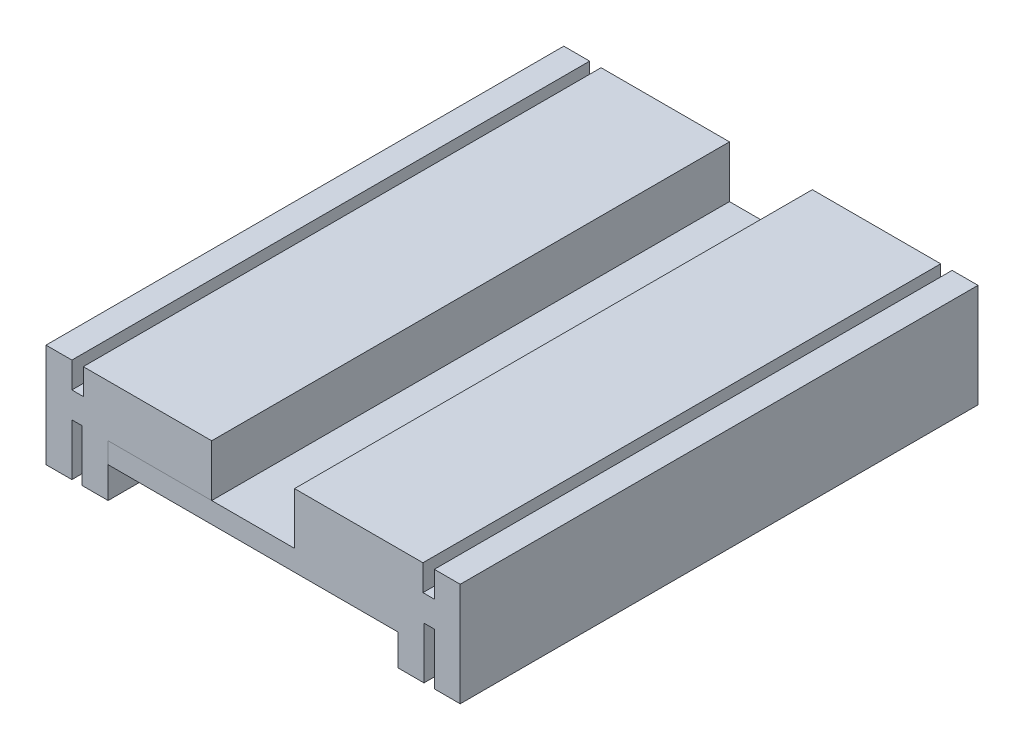
from build123d import *

# Parameters (mm, degrees)
EXTRU_MINCE1_DEPTH      = 100
ESQUISSE4_W             = 2.2
ESQUISSE4_H             = 100
ENL_V_MAT_EXTRU_1_DEPTH = 5
ESQUISSE7_W             = 5
ESQUISSE7_H             = 100
BOSS_EXTRU_1_DEPTH      = 10
ESQUISSE8_W             = 16
ESQUISSE8_H             = 100
ENL_V_MAT_EXTRU_3_DEPTH = 11
ESQUISSE9_W             = 56
ESQUISSE9_H             = 100
BOSS_EXTRU_2_DEPTH      = 4


with BuildPart() as part:
    # Esquisse2 → Extru.-Mince1 (new body)
    with BuildSketch(Plane.XY):
        Polygon((-40, 0), (-10, 0), (10, 0), (40, 0), (40, -10), (10, -10), (-10, -10), (-40, -10), align=None)
    extrude(amount=EXTRU_MINCE1_DEPTH)

    # Esquisse4 → Enlèv. mat.-Extru.1 (cut)
    with BuildSketch(Plane(origin=(0, 0, 0), x_dir=(1, 0, 0), z_dir=(0, 1, 0))):
        with Locations((-33.9, -50)):
            Rectangle(ESQUISSE4_W, ESQUISSE4_H)
        with Locations((33.9, -50)):
            Rectangle(ESQUISSE4_W, ESQUISSE4_H)
    extrude(amount=-ENL_V_MAT_EXTRU_1_DEPTH, mode=Mode.SUBTRACT)

    # Esquisse7 → Boss.-Extru.1 (add)
    with BuildSketch(Plane.XZ.offset(10)):
        with Locations((-37.5, 50)):
            Rectangle(ESQUISSE7_W, ESQUISSE7_H)
        with Locations((-30.5, 50)):
            Rectangle(ESQUISSE7_W, ESQUISSE7_H)
        with Locations((37.5, 50)):
            Rectangle(ESQUISSE7_W, ESQUISSE7_H)
        with Locations((30.5, 50)):
            Rectangle(ESQUISSE7_W, ESQUISSE7_H)
    extrude(amount=BOSS_EXTRU_1_DEPTH)

    # Esquisse8 → Enlèv. mat.-Extru.3 (cut)
    with BuildSketch(Plane(origin=(0, 0, 0), x_dir=(1, 0, 0), z_dir=(0, 1, 0))):
        with Locations((0, -50)):
            Rectangle(ESQUISSE8_W, ESQUISSE8_H)
    extrude(amount=-ENL_V_MAT_EXTRU_3_DEPTH, mode=Mode.SUBTRACT)


with BuildPart() as enl_v_mat_extru_3_piece_1:
    # of the separate pieces the step leaves, piece 1, a body of its own (enl_v_mat_extru_3_pieces)
    add(part.part.solids().sort_by_distance((40, 0, 0))[0])

    # Esquisse9 → Boss.-Extru.2 (add)
    with BuildSketch(Plane.XZ.offset(10)):
        with Locations((0, 50)):
            Rectangle(ESQUISSE9_W, ESQUISSE9_H)
    extrude(amount=BOSS_EXTRU_2_DEPTH)


with BuildPart() as enl_v_mat_extru_3_piece_2:
    # of the separate pieces the step leaves, piece 2, a body of its own (enl_v_mat_extru_3_pieces)
    add(part.part.solids().sort_by_distance((-35, 0, 0))[0])


solid = Compound([enl_v_mat_extru_3_piece_1.part, enl_v_mat_extru_3_piece_2.part])
